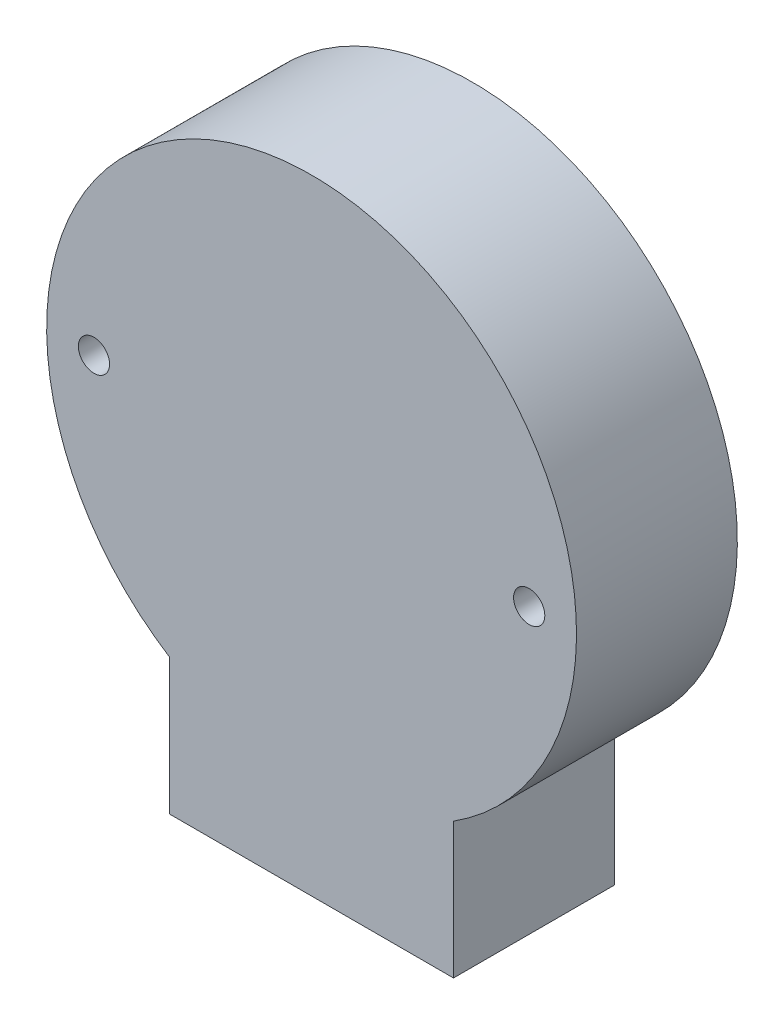
from build123d import *

# Parameters (mm, degrees)
BOSS_EXTRUDE1_DEPTH            = 17
F_3_3_3_3_DIAMETER_HOLE1_D     = 3.3
F_3_3_3_3_DIAMETER_HOLE1_DEPTH = 25
F_3_3_3_3_DIAMETER_HOLE1_TIP   = 0.991420021


with BuildPart() as part:
    # Sketch1 → Boss-Extrude1 (new body)
    with BuildSketch(Plane.XY):
        with BuildLine():
            Line((-15, -23.643180835), (-15, -38))
            Line((-15, -38), (15, -38))
            Line((15, -38), (15, -23.643180835))
            ThreePointArc((15, -23.643180835), (0, 28), (-15, -23.643180835))
        make_face()
    extrude(amount=BOSS_EXTRUDE1_DEPTH)

    # Ø3.3 (3.3) Diameter Hole1
    with Locations(Plane.XY.offset(17)):
        with Locations((-23, 0), (23, 0)):
            Hole(F_3_3_3_3_DIAMETER_HOLE1_D / 2, depth=F_3_3_3_3_DIAMETER_HOLE1_DEPTH)
            with Locations((0, 0, -(F_3_3_3_3_DIAMETER_HOLE1_DEPTH + F_3_3_3_3_DIAMETER_HOLE1_TIP / 2))):  # 118° drill point
                Cone(0, F_3_3_3_3_DIAMETER_HOLE1_D / 2, F_3_3_3_3_DIAMETER_HOLE1_TIP, mode=Mode.SUBTRACT)


solid = part.part
